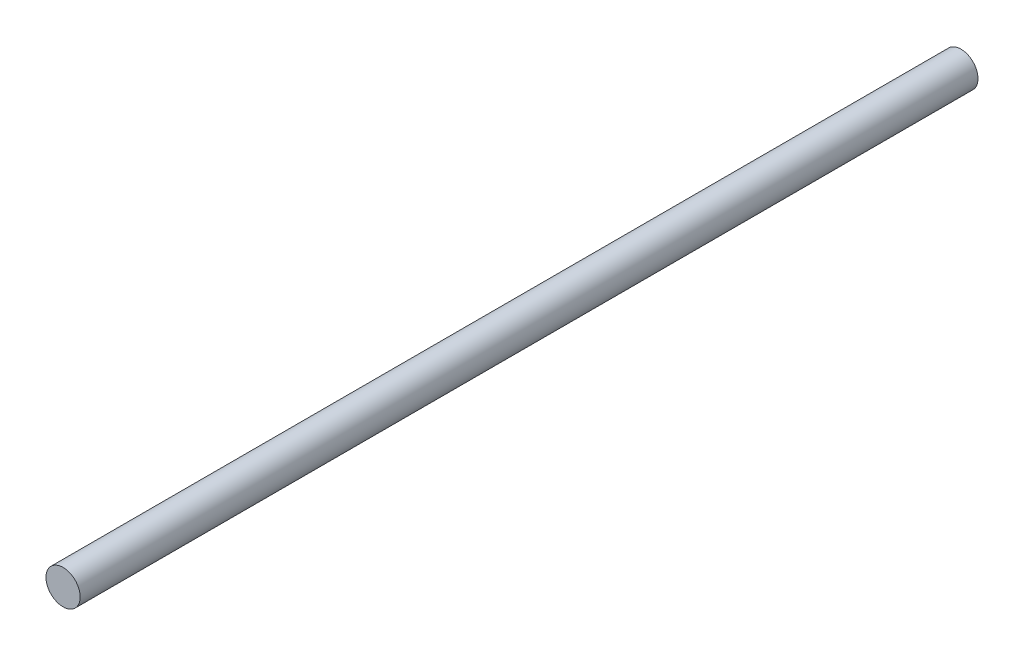
from build123d import *

# Parameters (mm, degrees)
ESBO_O1_R                = 4
RESSALTO_EXTRUS_O1_DEPTH = 210


with BuildPart() as part:
    # Esboço1 → Ressalto-extrusão1 (new body)
    with BuildSketch(Plane.XY):
        Circle(ESBO_O1_R)
    extrude(amount=RESSALTO_EXTRUS_O1_DEPTH)


solid = part.part
